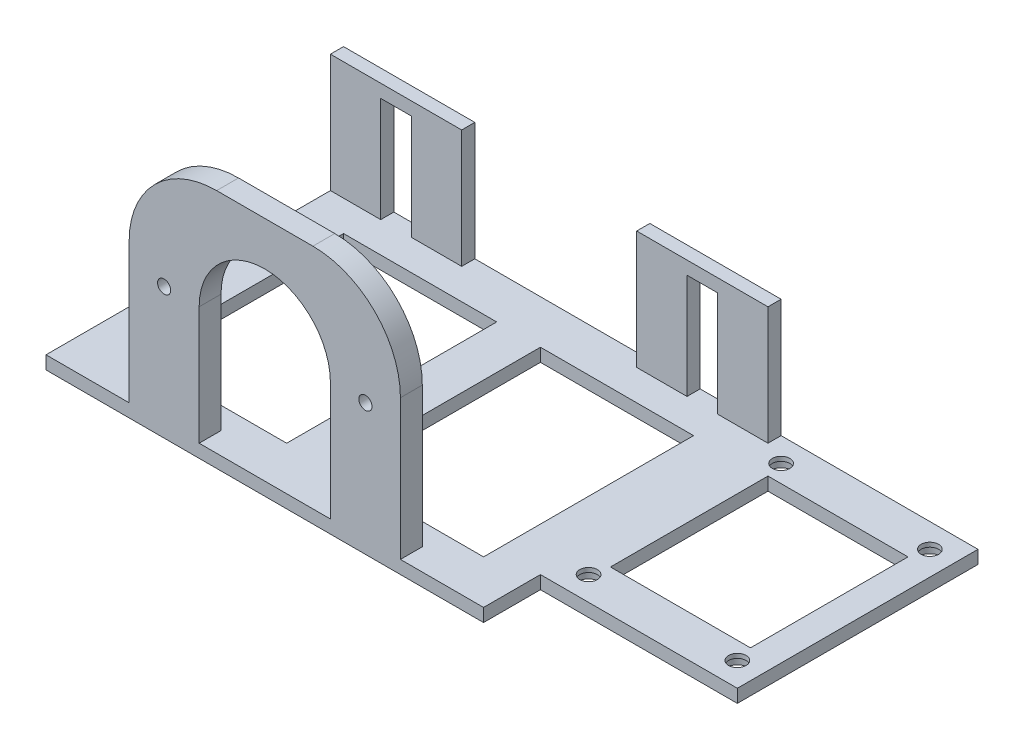
from build123d import *

# Parameters (mm, degrees)
SKETCH_1_W          = 100
SKETCH_1_H          = 68
EXTRUDE_1_DEPTH     = 3
SKETCH_2_W          = 100
SKETCH_2_H          = 3
EXTRUDE_2_DEPTH     = 27
SKETCH_3_W          = 7
SKETCH_3_H          = 24
CUT_EXTRUDE_2_DEPTH = 27
SKETCH_4_W          = 62
SKETCH_4_H          = 5
EXTRUDE_3_DEPTH     = 52
SKETCH_5_R          = 1.5
CUT_EXTRUDE_4_DEPTH = 5
SKETCH_7_W          = 35
SKETCH_7_H          = 48
CUT_EXTRUDE_5_DEPTH = 3
SKETCH_8_W          = 55
SKETCH_8_H          = 3
EXTRUDE_4_DEPTH     = 45
SKETCH_10_R         = 2
SKETCH_10_W         = 32
SKETCH_10_H         = 36
CUT_EXTRUDE_6_DEPTH = 45
SKETCH_12_R         = 3
CUT_EXTRUDE_7_DEPTH = 2
SKETCH_13_W         = 40
SKETCH_13_H         = 27
CUT_EXTRUDE_8_DEPTH = 10
FILLET_1_R          = 20


with BuildPart() as part:
    # 스케치1 → 보스-돌출1 (new body)
    with BuildSketch(Plane(origin=(0, 0, 0), x_dir=(1, 0, 0), z_dir=(0, 1, 0))):
        Rectangle(SKETCH_1_W, SKETCH_1_H)
    extrude(amount=EXTRUDE_1_DEPTH)

    # 스케치2 → 보스-돌출2 (add)
    with BuildSketch(Plane(origin=(0, 3, 0), x_dir=(1, 0, 0), z_dir=(0, 1, 0))):
        with Locations((0, 32.5)):
            Rectangle(SKETCH_2_W, SKETCH_2_H)
    extrude(amount=EXTRUDE_2_DEPTH)

    # 스케치3 → 컷-돌출2 (cut)
    with BuildSketch(Plane.XY.offset(-31)):
        with Locations((-35, 15)):
            Rectangle(SKETCH_3_W, SKETCH_3_H)
        with Locations((35, 15)):
            Rectangle(SKETCH_3_W, SKETCH_3_H)
    extrude(amount=-CUT_EXTRUDE_2_DEPTH, mode=Mode.SUBTRACT)

    # 스케치4 → 보스-돌출3 (add)
    with BuildSketch(Plane(origin=(0, 3, 0), x_dir=(1, 0, 0), z_dir=(0, 1, 0))):
        with Locations((0, -31.5)):
            Rectangle(SKETCH_4_W, SKETCH_4_H)
    extrude(amount=EXTRUDE_3_DEPTH)

    # 스케치5 → 컷-돌출4 (cut)
    with BuildSketch(Plane.XY.offset(34)):
        with Locations((-23, 30)):
            Circle(SKETCH_5_R)
        with Locations((23, 30)):
            Circle(SKETCH_5_R)
        with BuildLine():
            Line((-15, 30), (-15, 3))
            Line((-15, 3), (15, 3))
            Line((15, 3), (15, 30))
            ThreePointArc((15, 30), (0, 45), (-15, 30))
        make_face()
    extrude(amount=-CUT_EXTRUDE_4_DEPTH, mode=Mode.SUBTRACT)

    # 스케치7 → 컷-돌출5 (cut)
    with BuildSketch(Plane.XZ):
        with Locations((22.5, 0)):
            Rectangle(SKETCH_7_W, SKETCH_7_H)
        with Locations((-22.5, 0)):
            Rectangle(SKETCH_7_W, SKETCH_7_H)
    extrude(amount=-CUT_EXTRUDE_5_DEPTH, mode=Mode.SUBTRACT)

    # 스케치8 → 보스-돌출4 (add)
    with BuildSketch(Plane(origin=(50, 0, 0), x_dir=(0, 0, -1), z_dir=(1, 0, 0))):
        with Locations((6.5, 1.5)):
            Rectangle(SKETCH_8_W, SKETCH_8_H)
    extrude(amount=EXTRUDE_4_DEPTH)

    # 스케치10 → 컷-돌출6 (cut)
    with BuildSketch(Plane(origin=(0, 3, 0), x_dir=(1, 0, 0), z_dir=(0, 1, 0))):
        with Locations((55.5, -15.5)):
            Circle(SKETCH_10_R)
        with Locations((55.5, 28.5)):
            Circle(SKETCH_10_R)
        with Locations((89.5, 28.5)):
            Circle(SKETCH_10_R)
        with Locations((89.5, -15.5)):
            Circle(SKETCH_10_R)
        with Locations((72.5, 6.5)):
            Rectangle(SKETCH_10_W, SKETCH_10_H)
    extrude(amount=-CUT_EXTRUDE_6_DEPTH, mode=Mode.SUBTRACT)

    # 스케치12 → 컷-돌출7 (cut)
    with BuildSketch(Plane.XZ):
        with Locations((89.5, -28.5)):
            Circle(SKETCH_12_R)
        with Locations((89.5, 15.5)):
            Circle(SKETCH_12_R)
        with Locations((55.5, 15.5)):
            Circle(SKETCH_12_R)
        with Locations((55.5, -28.5)):
            Circle(SKETCH_12_R)
    extrude(amount=-CUT_EXTRUDE_7_DEPTH, mode=Mode.SUBTRACT)

    # 스케치13 → 컷-돌출8 (cut)
    with BuildSketch(Plane(origin=(0, 0, -34), x_dir=(-1, 0, 0), z_dir=(0, 0, -1))):
        with Locations((0, 16.5)):
            Rectangle(SKETCH_13_W, SKETCH_13_H)
    extrude(amount=-CUT_EXTRUDE_8_DEPTH, mode=Mode.SUBTRACT)

    # 필렛1
    fillet_1_edges = [part.edges().sort_by_distance(p)[0] for p in [
        (31, 55, 31.5),
        (-31, 55, 31.5),
    ]]
    fillet(fillet_1_edges, radius=FILLET_1_R)


solid = part.part
